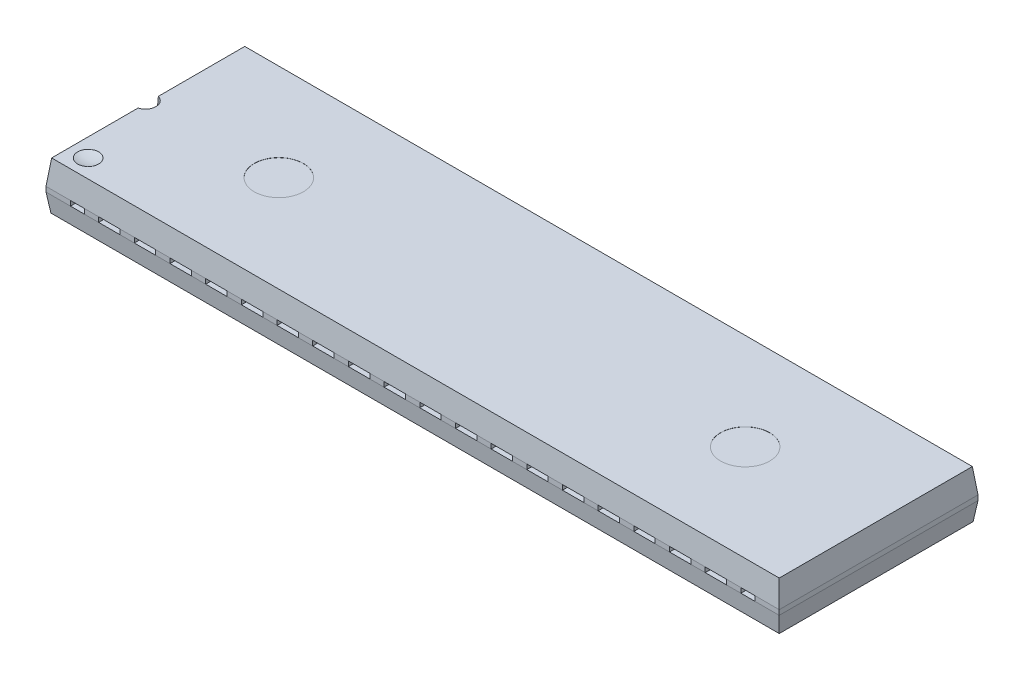
from build123d import *

# Parameters (mm, degrees)
SKETCH2_W      = 51.8
SKETCH2_H      = 13.75
SKETCH1_W      = 52.2
SKETCH1_H      = 14.15
SKETCH3_W      = 52.2
SKETCH3_H      = 14.15
EXTRUDE1_DEPTH = 0.35
SKETCH4_W      = 52.2
SKETCH4_H      = 14.15
SKETCH5_W      = 51.85
SKETCH5_H      = 13.8
SKETCH7_R      = 0.75
EXTRUDE2_DEPTH = 0.75
SKETCH11_W     = 1.524
SKETCH11_H     = 0.35
SKETCH11_W_2   = 0.9906
EXTRUDE3_DEPTH = 1
SKETCH12_R     = 1.75
EXTRUDE4_DEPTH = 0.01


with BuildPart() as part:
    # Sketch2 → Loft1 section 0
    with BuildSketch(Plane(origin=(0, 1.75, 0), x_dir=(-1, 0, 0), z_dir=(0, 1, 0))):
        Rectangle(SKETCH2_W, SKETCH2_H)
    # Sketch1 → Loft1 section 1
    with BuildSketch(Plane(origin=(0, 0, 0), x_dir=(1, 0, 0), z_dir=(0, 1, 0))):
        Rectangle(SKETCH1_W, SKETCH1_H)
    loft()

    # Sketch3 → Extrude1 (add)
    with BuildSketch(Plane.XZ):
        Rectangle(SKETCH3_W, SKETCH3_H)
    extrude(amount=EXTRUDE1_DEPTH)

    # Sketch4 → Loft2 section 0
    with BuildSketch(Plane.XZ.offset(0.35)):
        Rectangle(SKETCH4_W, SKETCH4_H)
    # Sketch5 → Loft2 section 1
    with BuildSketch(Plane(origin=(0, -1.65, 0), x_dir=(-1, 0, 0), z_dir=(0, 1, 0))):
        Rectangle(SKETCH5_W, SKETCH5_H)
    loft()

    # Sketch7 → Extrude2 (cut)
    with BuildSketch(Plane(origin=(0, 1.75, 0), x_dir=(1, 0, 0), z_dir=(0, 1, 0))):
        with Locations((-26.1, 0)):
            Circle(SKETCH7_R)
    extrude(amount=-EXTRUDE2_DEPTH, mode=Mode.SUBTRACT)

    # Sketch10 → Cut-Revolve1 (revolve, cut)
    with BuildSketch(Plane.XY.offset(5.575)):
        with BuildLine():
            Line((-24.6, 6.25), (-24.6, 1.625))
            ThreePointArc((-24.6, 1.625), (-26.9125, 3.9375), (-24.6, 6.25))
        make_face()
    revolve(axis=Axis((-24.6, 6.25, 5.575), (0, -1, 0)), mode=Mode.SUBTRACT)

    # Sketch11 → Extrude3 (cut)
    with BuildSketch(Plane.XY.offset(7.075)):
        with Locations((-3.81, -0.175)):
            Rectangle(SKETCH11_W, SKETCH11_H)
        with Locations((-1.27, -0.175)):
            Rectangle(SKETCH11_W, SKETCH11_H)
        with Locations((1.27, -0.175)):
            Rectangle(SKETCH11_W, SKETCH11_H)
        with Locations((3.80999999, -0.175229628)):
            Rectangle(SKETCH11_W, SKETCH11_H)
        with Locations((6.349999979, -0.175459257)):
            Rectangle(SKETCH11_W, SKETCH11_H)
        with Locations((8.889999969, -0.175688885)):
            Rectangle(SKETCH11_W, SKETCH11_H)
        with Locations((11.429999958, -0.175918514)):
            Rectangle(SKETCH11_W, SKETCH11_H)
        with Locations((13.969999948, -0.176148142)):
            Rectangle(SKETCH11_W, SKETCH11_H)
        with Locations((16.509999938, -0.17637777)):
            Rectangle(SKETCH11_W, SKETCH11_H)
        with Locations((19.049999927, -0.176607399)):
            Rectangle(SKETCH11_W, SKETCH11_H)
        with Locations((21.589999917, -0.176837027)):
            Rectangle(SKETCH11_W, SKETCH11_H)
        with Locations((23.863299907, -0.177066655)):
            Rectangle(SKETCH11_W_2, SKETCH11_H)
        with Locations((-6.35, -0.175)):
            Rectangle(SKETCH11_W, SKETCH11_H)
        with Locations((-8.89, -0.175)):
            Rectangle(SKETCH11_W, SKETCH11_H)
        with Locations((-11.43, -0.175)):
            Rectangle(SKETCH11_W, SKETCH11_H)
        with Locations((-13.97, -0.175)):
            Rectangle(SKETCH11_W, SKETCH11_H)
        with Locations((-16.51, -0.175)):
            Rectangle(SKETCH11_W, SKETCH11_H)
        with Locations((-19.05, -0.175)):
            Rectangle(SKETCH11_W, SKETCH11_H)
        with Locations((-21.59, -0.175)):
            Rectangle(SKETCH11_W, SKETCH11_H)
        with Locations((-23.8633, -0.175)):
            Rectangle(SKETCH11_W_2, SKETCH11_H)
    extrude3 = extrude(amount=-EXTRUDE3_DEPTH, mode=Mode.SUBTRACT)

    # Mirror1: Extrude3 across plane
    add(extrude3.mirror(Plane.XY), mode=Mode.SUBTRACT)

    # Sketch12 → Extrude4 (cut)
    with BuildSketch(Plane(origin=(0, 1.75, 0), x_dir=(1, 0, 0), z_dir=(0, 1, 0))):
        with Locations(Location((-16.6, 0, 0), (0, 0, 270))):  # turned: the seam where the file's is
            Circle(SKETCH12_R)
        with Locations(Location((16.6, 0, 0), (0, 0, 270))):  # turned: the seam where the file's is
            Circle(SKETCH12_R)
    extrude(amount=-EXTRUDE4_DEPTH, mode=Mode.SUBTRACT)


solid = part.part
